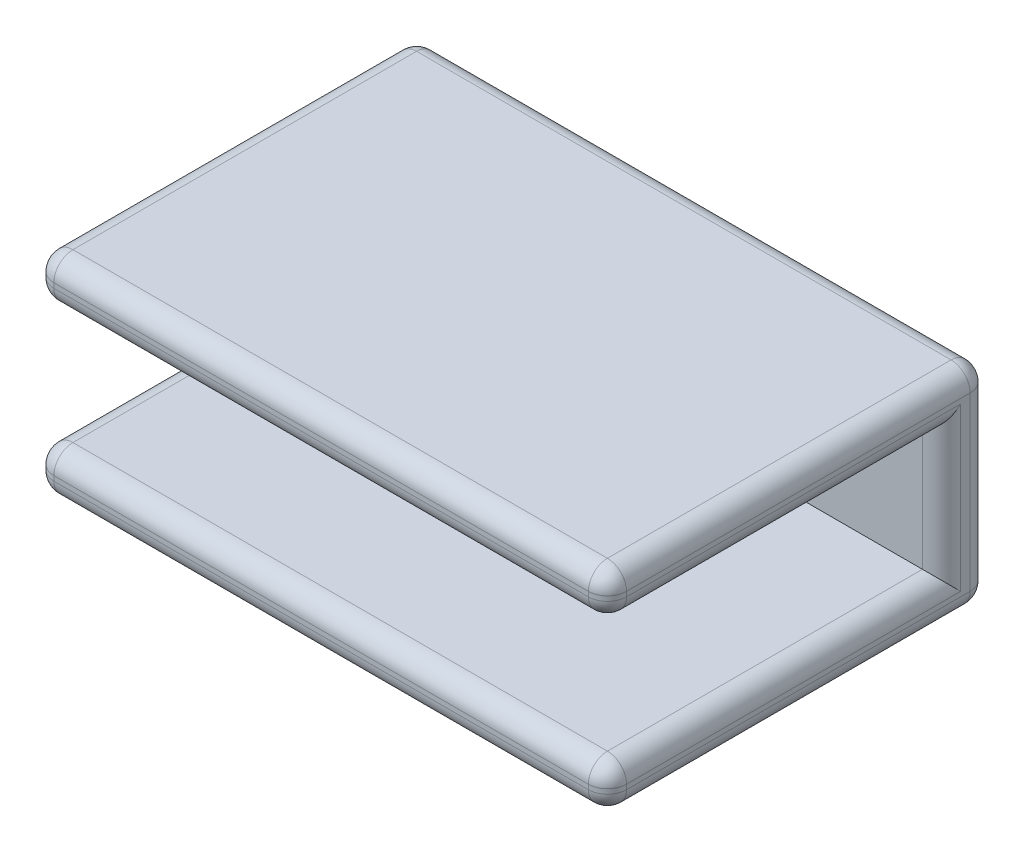
from build123d import *

# Parameters (mm, degrees)
SKETCH1_W           = 30
SKETCH1_H           = 20
BOSS_EXTRUDE1_DEPTH = 11
SKETCH2_W           = 30
SKETCH2_H           = 6.5
CUT_EXTRUDE1_DEPTH  = 17.5
FILLET1_R           = 1


with BuildPart() as part:
    # Sketch1 → Boss-Extrude1 (new body)
    with BuildSketch(Plane(origin=(0, 0, 0), x_dir=(1, 0, 0), z_dir=(0, 1, 0))):
        Rectangle(SKETCH1_W, SKETCH1_H)
    extrude(amount=BOSS_EXTRUDE1_DEPTH)

    # Sketch2 → Cut-Extrude1 (cut)
    with BuildSketch(Plane.XY.offset(10)):
        with Locations((0, 5.5)):
            Rectangle(SKETCH2_W, SKETCH2_H)
    extrude(amount=-CUT_EXTRUDE1_DEPTH, mode=Mode.SUBTRACT)

    # Fillet1
    fillet1_edges = [part.edges().sort_by_distance(p)[0] for p in [
        (-15, 11, 0),
        (0, 11, 10),
        (15, 1.125, 10),
        (-15, 1.125, 10),
        (-15, 8.75, 1.25),
        (15, 5.5, -7.5),
        (15, 8.75, 1.25),
        (15, 2.25, 1.25),
        (-15, 5.5, -7.5),
        (-15, 2.25, 1.25),
        (0, 8.75, 10),
        (0, 2.25, 10),
        (15, 11, 0),
        (0, 0, 10),
        (-15, 0, 0),
        (0, 0, -10),
        (15, 0, 0),
        (0, 11, -10),
        (15, 9.875, 10),
        (-15, 9.875, 10),
        (-15, 5.5, -10),
        (15, 5.5, -10),
    ]]
    fillet(fillet1_edges, radius=FILLET1_R)


solid = part.part
